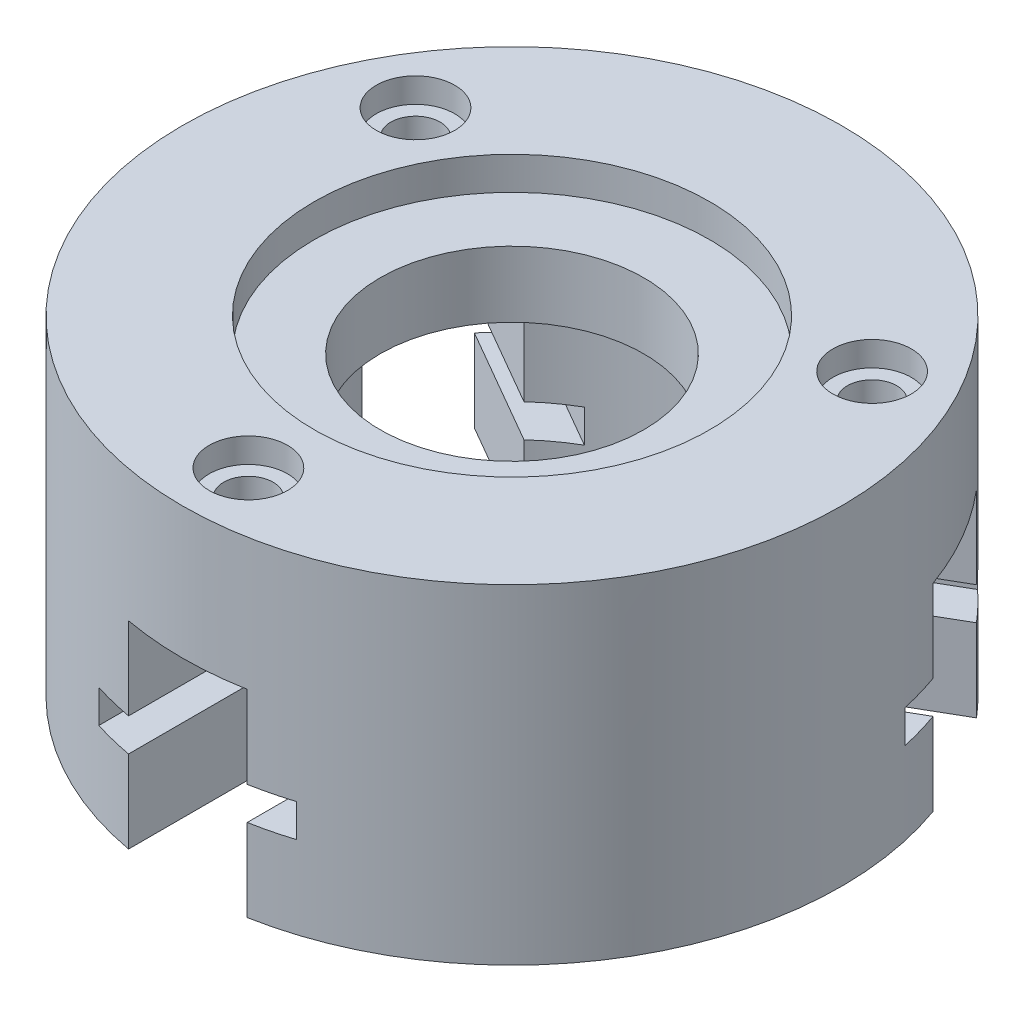
from build123d import *

# Parameters (mm, degrees)
SKETCH6_R                                = 100
SKETCH6_R_2                              = 40
BOSS_EXTRUDE2_DEPTH                      = 50
SKETCH7_R                                = 60
CUT_EXTRUDE4_DEPTH                       = 10
SKETCH8_R                                = 60
CUT_EXTRUDE5_DEPTH                       = 70
CUT_EXTRUDE6_DEPTH                       = 101
CBORE_FOR_M12_HEX_HEAD_BOLT1_D           = 15
CBORE_FOR_M12_HEX_HEAD_BOLT1_CBORE_D     = 23.785
CBORE_FOR_M12_HEX_HEAD_BOLT1_CBORE_DEPTH = 7.5
CIRPATTERN2_COUNT                        = 3


with BuildPart() as part:
    # Sketch6 → Boss-Extrude2 (new body, symmetric)
    with BuildSketch(Plane(origin=(0, 0, 0), x_dir=(0, 0, -1), z_dir=(0, 1, 0))):
        with Locations(Location((0, 0, 0), (0, 0, 180))):  # turned: the seam where the file's is
            Circle(SKETCH6_R)
        with Locations(Location((0, 0, 0), (0, 0, 180))):  # turned: the seam where the file's is
            Circle(SKETCH6_R_2, mode=Mode.SUBTRACT)
    extrude(amount=BOSS_EXTRUDE2_DEPTH, both=True)

    # Sketch7 → Cut-Extrude4 (cut)
    with BuildSketch(Plane(origin=(0, 50, 0), x_dir=(0, 0, -1), z_dir=(0, 1, 0))):
        with Locations(Location((0, 0, 0), (0, 0, 90))):  # turned: the seam where the file's is
            Circle(SKETCH7_R)
    extrude(amount=-CUT_EXTRUDE4_DEPTH, mode=Mode.SUBTRACT)

    # Sketch8 → Cut-Extrude5 (cut)
    with BuildSketch(Plane(origin=(0, -50, 0), x_dir=(0, 0, 1), z_dir=(0, -1, 0))):
        with Locations(Location((0, 0, 0), (0, 0, 90))):  # turned: the seam where the file's is
            Circle(SKETCH8_R)
    extrude(amount=-CUT_EXTRUDE5_DEPTH, mode=Mode.SUBTRACT)

    # Sketch9 → Cut-Extrude6 (cut, through all)
    with BuildSketch(Plane(origin=(0, 0, 0), x_dir=(0, -1, 0), z_dir=(0, 0, 1))):
        Polygon((50, -18), (50, 18), (25, 18), (25, 30), (15, 30), (15, 18), (-10, 18), (-10, -18), (15, -18), (15, -30), (25, -30), (25, -18), align=None)
    cut_extrude6 = extrude(amount=CUT_EXTRUDE6_DEPTH, mode=Mode.SUBTRACT)

    # CBORE for M12 Hex Head Bolt1 (through all)
    with Locations(Plane(origin=(0, 50, 0), x_dir=(1, 0, 0), z_dir=(0, 1, 0))):
        with Locations((0, -80)):
            cbore_for_m12_hex_head_bolt1 = CounterBoreHole(CBORE_FOR_M12_HEX_HEAD_BOLT1_D / 2, CBORE_FOR_M12_HEX_HEAD_BOLT1_CBORE_D / 2, CBORE_FOR_M12_HEX_HEAD_BOLT1_CBORE_DEPTH)

    # CirPattern2: Cut-Extrude6, CBORE for M12 Hex Head Bolt1 ×3 about axis
    cirpattern2_axis = Axis((0, 0, 0), (0, 1, 0))
    add([cut_extrude6.rotate(cirpattern2_axis, i * 360 / CIRPATTERN2_COUNT) for i in range(1, CIRPATTERN2_COUNT)], mode=Mode.SUBTRACT)
    add([cbore_for_m12_hex_head_bolt1.rotate(cirpattern2_axis, i * 360 / CIRPATTERN2_COUNT) for i in range(1, CIRPATTERN2_COUNT)], mode=Mode.SUBTRACT)


solid = part.part
